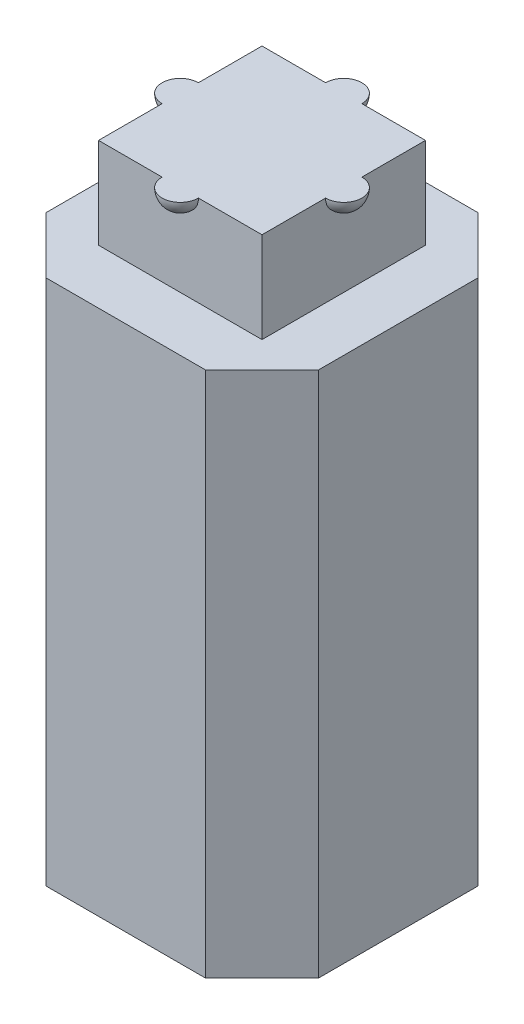
from build123d import *

# Parameters (mm, degrees)
EXTRUDE_1_DEPTH     = 4
EXTRUDE_2_DEPTH     = 10.5
SKETCH_3_W          = 4.5
SKETCH_3_H          = 4.5
EXTRUDE_3_DEPTH     = 2.5
SKETCH_6_W          = 5.635445318
SKETCH_6_H          = 5.939696962
CUT_EXTRUDE_2_DEPTH = 2.5


with BuildPart() as part:
    # 草图1 → 凸台-拉伸1 (new body)
    with BuildSketch(Plane(origin=(0, 0, 0), x_dir=(1, 0, 0), z_dir=(0, 1, 0))):
        Polygon((2.189696962, -3.75), (3.75, -2.189696962), (3.75, 2.189696962), (2.189696962, 3.75), (-2.189696962, 3.75), (-3.75, 2.189696962), (-3.75, -2.189696962), (-2.189696962, -3.75), align=None)
        with BuildLine():
            Line((2.25, -0.4), (2.25, -2.25))
            Line((2.25, -2.25), (0.4, -2.25))
            ThreePointArc((0.4, -2.25), (0, -2.65), (-0.4, -2.25))
            Line((-0.4, -2.25), (-2.25, -2.25))
            Line((-2.25, -2.25), (-2.25, -0.4))
            ThreePointArc((-2.25, -0.4), (-2.65, 0), (-2.25, 0.4))
            Line((-2.25, 0.4), (-2.25, 2.25))
            Line((-2.25, 2.25), (-0.4, 2.25))
            ThreePointArc((-0.4, 2.25), (0, 2.65), (0.4, 2.25))
            Line((0.4, 2.25), (2.25, 2.25))
            Line((2.25, 2.25), (2.25, 0.4))
            ThreePointArc((2.25, 0.4), (2.65, 0), (2.25, -0.4))
        make_face(mode=Mode.SUBTRACT)
    extrude(amount=EXTRUDE_1_DEPTH)

    # 草图2 → 凸台-拉伸2 (add)
    with BuildSketch(Plane(origin=(0, 4, 0), x_dir=(1, 0, 0), z_dir=(0, 1, 0))):
        Polygon((-2.189696962, -3.75), (2.189696962, -3.75), (3.75, -2.189696962), (3.75, 2.189696962), (2.189696962, 3.75), (-2.189696962, 3.75), (-3.75, 2.189696962), (-3.75, -2.189696962), align=None)
    extrude(amount=EXTRUDE_2_DEPTH)

    # 草图3 → 凸台-拉伸3 (add)
    with BuildSketch(Plane(origin=(0, 14.5, 0), x_dir=(1, 0, 0), z_dir=(0, 1, 0))):
        Rectangle(SKETCH_3_W, SKETCH_3_H)
    extrude(amount=EXTRUDE_3_DEPTH)

    # 草图4 → 旋转1 (revolve)
    with BuildSketch(Plane(origin=(0, 17, 0), x_dir=(1, 0, 0), z_dir=(0, 1, 0))):
        with BuildLine():
            Line((0, 2.75), (0, 1.75))
            ThreePointArc((0, 1.75), (-0.5, 2.25), (0, 2.75))
        make_face()
        with BuildLine():
            Line((0, -1.75), (0, -2.75))
            ThreePointArc((0, -2.75), (-0.5, -2.25), (0, -1.75))
        make_face()
    revolve(axis=Axis((0, 17, -2.75), (0, 0, 1)))

    # 草图5 → 旋转2 (revolve)
    with BuildSketch(Plane(origin=(0, 17, 0), x_dir=(1, 0, 0), z_dir=(0, 1, 0))):
        with BuildLine():
            Line((-2.75, 0), (-1.75, 0))
            ThreePointArc((-1.75, 0), (-2.25, -0.5), (-2.75, 0))
        make_face()
        with BuildLine():
            Line((1.75, 0), (2.75, 0))
            ThreePointArc((2.75, 0), (2.25, -0.5), (1.75, 0))
        make_face()
    revolve(axis=Axis((-2.75, 17, 0), (1, 0, 0)))

    # 草图6 → 切除-拉伸2 (cut)
    with BuildSketch(Plane(origin=(0, 17, 0), x_dir=(1, 0, 0), z_dir=(0, 1, 0))):
        Rectangle(SKETCH_6_W, SKETCH_6_H)
    extrude(amount=CUT_EXTRUDE_2_DEPTH, mode=Mode.SUBTRACT)


solid = part.part
